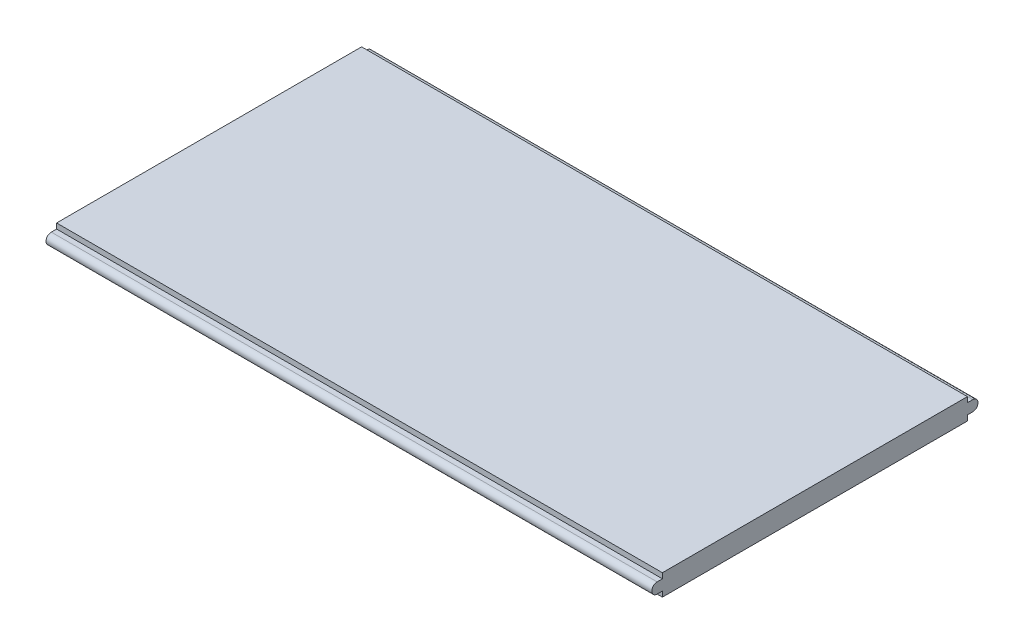
from build123d import *

# Parameters (mm, degrees)
BOSS_EXTRUDE1_DEPTH = 1430


with BuildPart() as part:
    # Sketch1 → Boss-Extrude1 (new body)
    with BuildSketch(Plane(origin=(0, 0, 0), x_dir=(0, 0, -1), z_dir=(1, 0, 0))):
        with BuildLine():
            Line((360, 25), (-360, 25))
            Line((-360, 25), (-360, 12.5))
            Line((-360, 12.5), (-347.5, 12.5))
            ThreePointArc((-347.5, 12.5), (-335, 0), (-347.5, -12.5))
            Line((-347.5, -12.5), (-360, -12.5))
            Line((-360, -12.5), (-360, -25))
            Line((-360, -25), (360, -25))
            Line((360, -25), (360, -12.5))
            Line((360, -12.5), (347.5, -12.5))
            ThreePointArc((347.5, -12.5), (335, 0), (347.5, 12.5))
            Line((347.5, 12.5), (360, 12.5))
            Line((360, 12.5), (360, 25))
        make_face()
        with BuildLine():
            Line((-347.5, 12.5), (-360, 12.5))
            Line((-360, 12.5), (-360, -12.5))
            Line((-360, -12.5), (-347.5, -12.5))
            ThreePointArc((-347.5, -12.5), (-335, 0), (-347.5, 12.5))
        make_face()
        with BuildLine():
            Line((-360, -12.5), (-360, 12.5))
            Line((-360, 12.5), (-372.5, 12.5))
            ThreePointArc((-372.5, 12.5), (-385, 0), (-372.5, -12.5))
            Line((-372.5, -12.5), (-360, -12.5))
        make_face()
        with BuildLine():
            Line((372.5, 12.5), (360, 12.5))
            Line((360, 12.5), (360, -12.5))
            Line((360, -12.5), (372.5, -12.5))
            ThreePointArc((372.5, -12.5), (385, 0), (372.5, 12.5))
        make_face()
        with BuildLine():
            Line((360, -12.5), (360, 12.5))
            Line((360, 12.5), (347.5, 12.5))
            ThreePointArc((347.5, 12.5), (335, 0), (347.5, -12.5))
            Line((347.5, -12.5), (360, -12.5))
        make_face()
    extrude(amount=BOSS_EXTRUDE1_DEPTH)


solid = part.part
